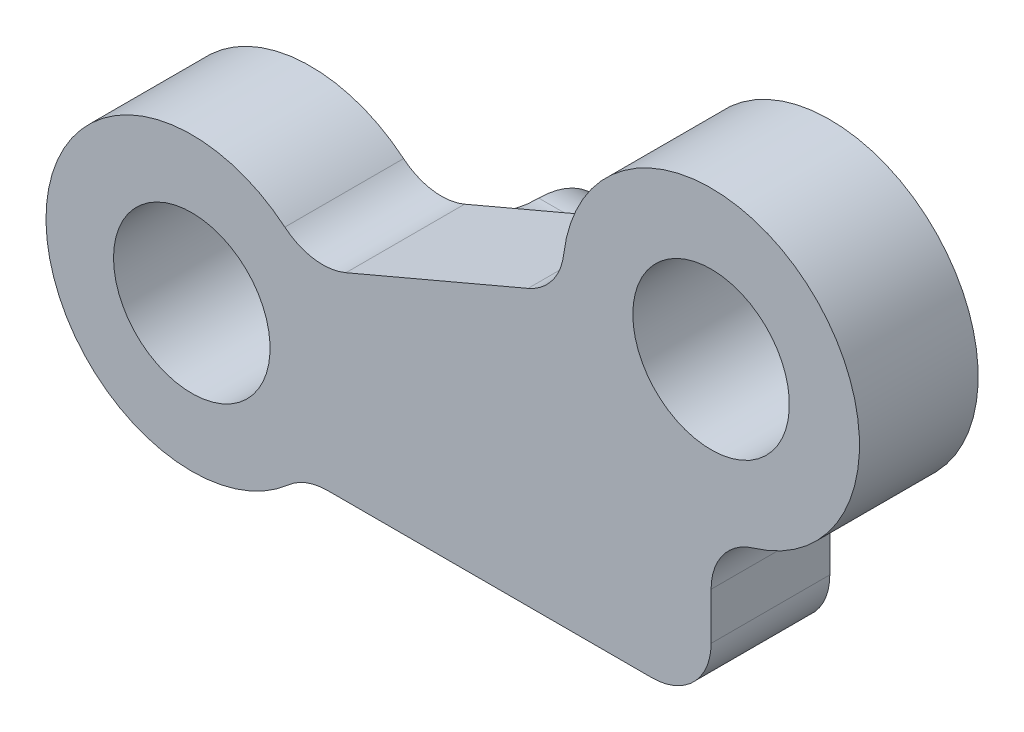
from build123d import *

# Parameters (mm, degrees)
BOSS_EXTRUDE3_DEPTH = 4
HOLE3_D             = 5.275
HOLE3_DEPTH         = 4
FILLET3_R           = 2
SKETCH25_R          = 1.506522666
BOSS_EXTRUDE4_DEPTH = 2


with BuildPart() as part:
    # Sketch17 → Boss-Extrude3 (new body)
    with BuildSketch(Plane(origin=(0, 0, 0), x_dir=(-1, 0, 0), z_dir=(0, 0, -1))):
        with BuildLine():
            Line((-43.273147001, 29.420937259), (-51.8645252, 33.076041142))
            ThreePointArc((-51.8645252, 33.076041142), (-60.191727201, 37.289326312), (-56.839071038, 28.579919803))
            Line((-56.839071038, 28.579919803), (-56.839071038, 23.292312115))
            Line((-56.839071038, 23.292312115), (-43.08257304, 23.292312115))
            ThreePointArc((-43.08257304, 23.292312115), (-34.429928081, 26.628647856), (-43.273147001, 29.420937259))
        make_face()
    extrude(amount=-BOSS_EXTRUDE3_DEPTH)

    # Hole3
    with Locations(Plane(origin=(0, 0, 0), x_dir=(-1, 0, 0), z_dir=(0, 0, -1))):
        with Locations((-39.340592987, 26.475947236), (-56.839071038, 33.579919803)):
            Hole(HOLE3_D / 2, depth=HOLE3_DEPTH)

    # Fillet3
    fillet3_edges = [part.edges().sort_by_distance(p)[0] for p in [
        (43.08257304, 23.292312115, 2),
        (56.839071038, 23.292312115, 2),
        (56.839071038, 28.579919803, 2),
        (51.8645252, 33.076041142, 2),
        (43.273147001, 29.420937259, 2),
    ]]
    fillet(fillet3_edges, radius=FILLET3_R)

    # Sketch25 → Boss-Extrude4 (add)
    with BuildSketch(Plane(origin=(47, 0, 0), x_dir=(0, 0, -1), z_dir=(1, 0, 0))):
        with BuildLine():
            Line((0, 23.292312115), (0, 30.144105031))
            add(Edge.make_bspline(
                [(2.034016737, 29.349553115), (0.844292257, 29.348828202), (0, 30.144105031)],
                knots=[0, 0, 0, 1, 1, 1], degree=2))
            ThreePointArc((2.034016737, 29.349553115), (4.534016737, 26.849553115), (2.034016737, 24.349553115))
            add(Edge.make_bspline(
                [(2.034016737, 24.349553115), (0.725821756, 24.359363318), (0, 23.292312115)],
                knots=[0, 0, 0, 1, 1, 1], degree=2))
        make_face()
        with Locations((2.034016737, 26.849553115)):
            Circle(SKETCH25_R, mode=Mode.SUBTRACT)
    extrude(amount=-BOSS_EXTRUDE4_DEPTH)


solid = part.part
